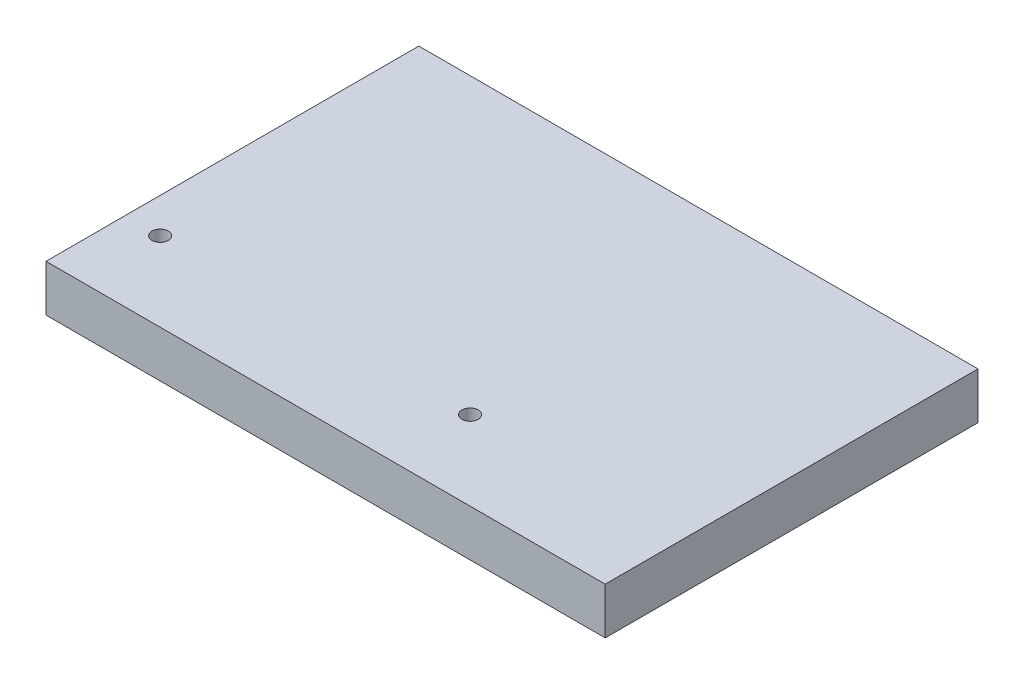
from build123d import *

# Parameters (mm, degrees)
SKETCH1_W           = 120
SKETCH1_H           = 80
BOSS_EXTRUDE1_DEPTH = 10
SKETCH2_R           = 1.75
CUT_EXTRUDE1_DEPTH  = 11
SKETCH3_R           = 3.25
CUT_EXTRUDE2_DEPTH  = 5


with BuildPart() as part:
    # Sketch1 → Boss-Extrude1 (new body)
    with BuildSketch(Plane.XZ.offset(-5100)):
        with Locations((-26.489460092, -13.07873573)):
            Rectangle(SKETCH1_W, SKETCH1_H)
    extrude(amount=BOSS_EXTRUDE1_DEPTH)

    # Sketch2 → Cut-Extrude1 (cut, through all)
    with BuildSketch(Plane.XZ.offset(-5090)):
        with Locations((-78.989460092, 9.92126427)):
            Circle(SKETCH2_R)
        with Locations((-12.489460092, 9.92126427)):
            Circle(SKETCH2_R)
    extrude(amount=-CUT_EXTRUDE1_DEPTH, mode=Mode.SUBTRACT)

    # Sketch3 → Cut-Extrude2 (cut)
    with BuildSketch(Plane.XZ.offset(-5090)):
        with Locations((-78.989460092, 9.92126427)):
            Circle(SKETCH3_R)
        with Locations((-12.489460092, 9.92126427)):
            Circle(SKETCH3_R)
    extrude(amount=-CUT_EXTRUDE2_DEPTH, mode=Mode.SUBTRACT)


solid = part.part
